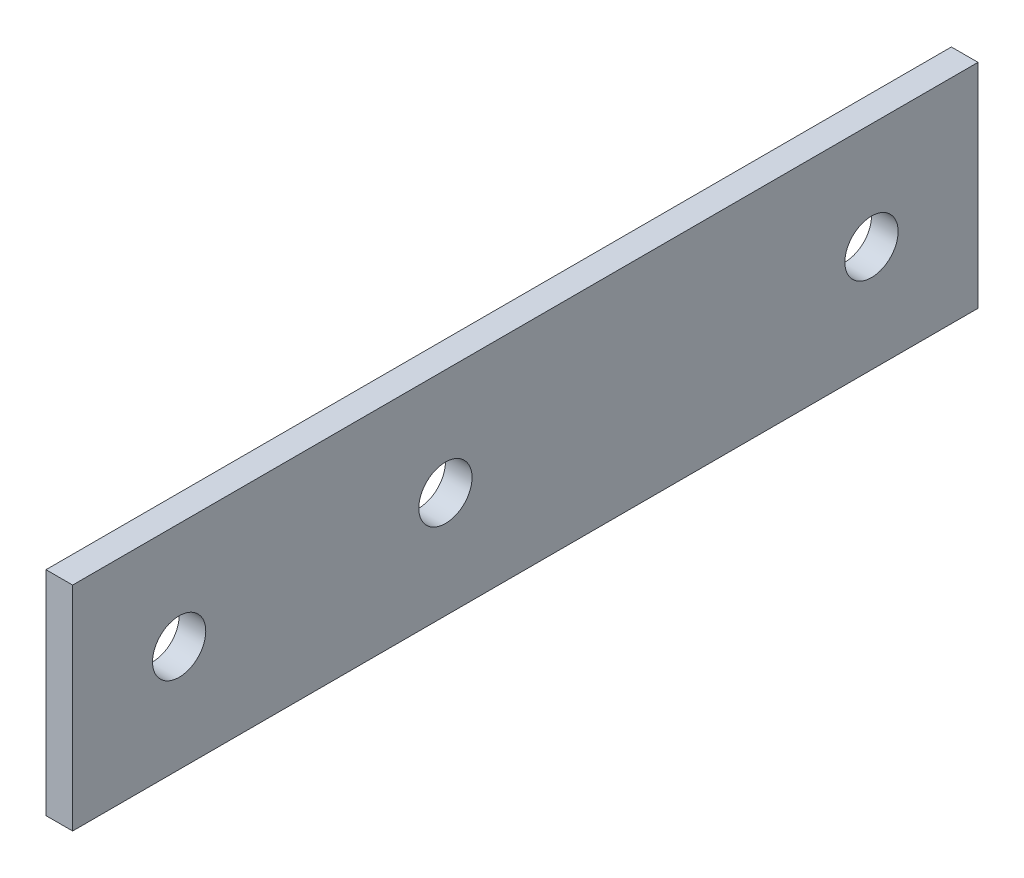
from build123d import *

# Parameters (mm, degrees)
SKETCH1_W           = 107.95
SKETCH1_H           = 25.4
BOSS_EXTRUDE1_DEPTH = 3.175
SKETCH2_R           = 3.175
CUT_EXTRUDE1_DEPTH  = 4.175


with BuildPart() as part:
    # Sketch1 → Boss-Extrude1 (new body)
    with BuildSketch(Plane(origin=(0, 0, 0), x_dir=(0, 0, -1), z_dir=(1, 0, 0))):
        Rectangle(SKETCH1_W, SKETCH1_H)
    extrude(amount=BOSS_EXTRUDE1_DEPTH)

    # Sketch2 → Cut-Extrude1 (cut, through all)
    with BuildSketch(Plane(origin=(3.175, 0, 0), x_dir=(0, 0, -1), z_dir=(1, 0, 0))):
        with Locations((41.275, 0)):
            Circle(SKETCH2_R)
        with Locations((-9.525, 0)):
            Circle(SKETCH2_R)
        with Locations((-41.275, 0)):
            Circle(SKETCH2_R)
    extrude(amount=-CUT_EXTRUDE1_DEPTH, mode=Mode.SUBTRACT)


solid = part.part
